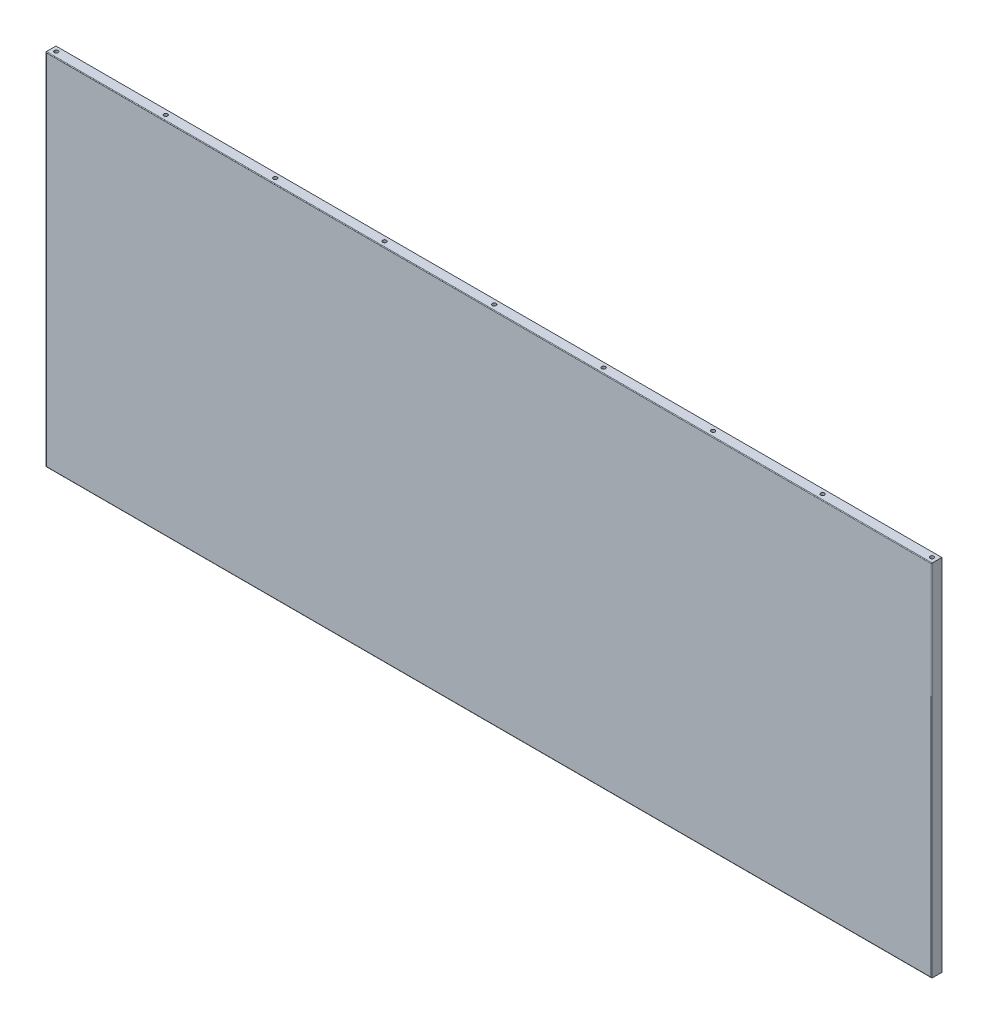
from build123d import *

# Parameters (mm, degrees)
SKETCH1_W               = 700
SKETCH1_H               = 284
BOSS_EXTRUDE1_DEPTH     = 8
FILLET1_R               = 0.5
SKETCH8_R               = 1.5
CUT_EXTRUDE6_DEPTH      = 20
LPATTERN4_COUNT         = 9
LPATTERN4_PITCH         = 86.5
MIRROR1_COPY_1_SKETCH_R = 1.5
MIRROR1_COPY_1_DEPTH    = 20
MIRROR1_COPY_2_SKETCH_R = 1.5
MIRROR1_COPY_2_DEPTH    = 20
MIRROR1_COPY_3_SKETCH_R = 1.5
MIRROR1_COPY_3_DEPTH    = 20
MIRROR1_COPY_4_SKETCH_R = 1.5
MIRROR1_COPY_4_DEPTH    = 20
MIRROR1_COPY_5_SKETCH_R = 1.5
MIRROR1_COPY_5_DEPTH    = 20
MIRROR1_COPY_6_SKETCH_R = 1.5
MIRROR1_COPY_6_DEPTH    = 20
MIRROR1_COPY_7_SKETCH_R = 1.5
MIRROR1_COPY_7_DEPTH    = 20
MIRROR1_COPY_8_SKETCH_R = 1.5
MIRROR1_COPY_8_DEPTH    = 20


with BuildPart() as part:
    # Sketch1 → Boss-Extrude1 (new body)
    with BuildSketch(Plane.XY):
        with Locations((350, 142)):
            Rectangle(SKETCH1_W, SKETCH1_H)
    extrude(amount=BOSS_EXTRUDE1_DEPTH)

    # Fillet1
    fillet1_edges = [part.edges().sort_by_distance(p)[0] for p in [
        (350, 284, 8),
        (700, 142, 8),
        (350, 0, 8),
        (0, 142, 8),
    ]]
    fillet(fillet1_edges, radius=FILLET1_R)

    # Sketch8 → Cut-Extrude6 (cut)
    with BuildSketch(Plane(origin=(0, 284, 0), x_dir=(1, 0, 0), z_dir=(0, 1, 0))):
        with Locations((4, -3.75)):
            Circle(SKETCH8_R)
    cut_extrude6 = extrude(amount=-CUT_EXTRUDE6_DEPTH, mode=Mode.SUBTRACT)

    # LPattern4: Cut-Extrude6 ×9
    with Locations(*[(i * LPATTERN4_PITCH, 0, 0) for i in range(1, LPATTERN4_COUNT)]):
        add(cut_extrude6, mode=Mode.SUBTRACT)

    # Mirror1: Cut-Extrude6 across plane
    add(cut_extrude6.mirror(Plane.ZX.offset(142)), mode=Mode.SUBTRACT)

    # Mirror1 copy 1 sketch → Mirror1 copy 1 (cut)
    with BuildSketch(Plane(origin=(86.5, 0, 0), x_dir=(1, 0, 0), z_dir=(0, -1, 0))):
        with Locations((4, 3.75)):
            Circle(MIRROR1_COPY_1_SKETCH_R)
    extrude(amount=-MIRROR1_COPY_1_DEPTH, mode=Mode.SUBTRACT)

    # Mirror1 copy 2 sketch → Mirror1 copy 2 (cut)
    with BuildSketch(Plane(origin=(173, 0, 0), x_dir=(1, 0, 0), z_dir=(0, -1, 0))):
        with Locations((4, 3.75)):
            Circle(MIRROR1_COPY_2_SKETCH_R)
    extrude(amount=-MIRROR1_COPY_2_DEPTH, mode=Mode.SUBTRACT)

    # Mirror1 copy 3 sketch → Mirror1 copy 3 (cut)
    with BuildSketch(Plane(origin=(259.5, 0, 0), x_dir=(1, 0, 0), z_dir=(0, -1, 0))):
        with Locations((4, 3.75)):
            Circle(MIRROR1_COPY_3_SKETCH_R)
    extrude(amount=-MIRROR1_COPY_3_DEPTH, mode=Mode.SUBTRACT)

    # Mirror1 copy 4 sketch → Mirror1 copy 4 (cut)
    with BuildSketch(Plane(origin=(346, 0, 0), x_dir=(1, 0, 0), z_dir=(0, -1, 0))):
        with Locations((4, 3.75)):
            Circle(MIRROR1_COPY_4_SKETCH_R)
    extrude(amount=-MIRROR1_COPY_4_DEPTH, mode=Mode.SUBTRACT)

    # Mirror1 copy 5 sketch → Mirror1 copy 5 (cut)
    with BuildSketch(Plane(origin=(432.5, 0, 0), x_dir=(1, 0, 0), z_dir=(0, -1, 0))):
        with Locations((4, 3.75)):
            Circle(MIRROR1_COPY_5_SKETCH_R)
    extrude(amount=-MIRROR1_COPY_5_DEPTH, mode=Mode.SUBTRACT)

    # Mirror1 copy 6 sketch → Mirror1 copy 6 (cut)
    with BuildSketch(Plane(origin=(519, 0, 0), x_dir=(1, 0, 0), z_dir=(0, -1, 0))):
        with Locations((4, 3.75)):
            Circle(MIRROR1_COPY_6_SKETCH_R)
    extrude(amount=-MIRROR1_COPY_6_DEPTH, mode=Mode.SUBTRACT)

    # Mirror1 copy 7 sketch → Mirror1 copy 7 (cut)
    with BuildSketch(Plane(origin=(605.5, 0, 0), x_dir=(1, 0, 0), z_dir=(0, -1, 0))):
        with Locations((4, 3.75)):
            Circle(MIRROR1_COPY_7_SKETCH_R)
    extrude(amount=-MIRROR1_COPY_7_DEPTH, mode=Mode.SUBTRACT)

    # Mirror1 copy 8 sketch → Mirror1 copy 8 (cut)
    with BuildSketch(Plane(origin=(692, 0, 0), x_dir=(1, 0, 0), z_dir=(0, -1, 0))):
        with Locations((4, 3.75)):
            Circle(MIRROR1_COPY_8_SKETCH_R)
    extrude(amount=-MIRROR1_COPY_8_DEPTH, mode=Mode.SUBTRACT)


solid = part.part
